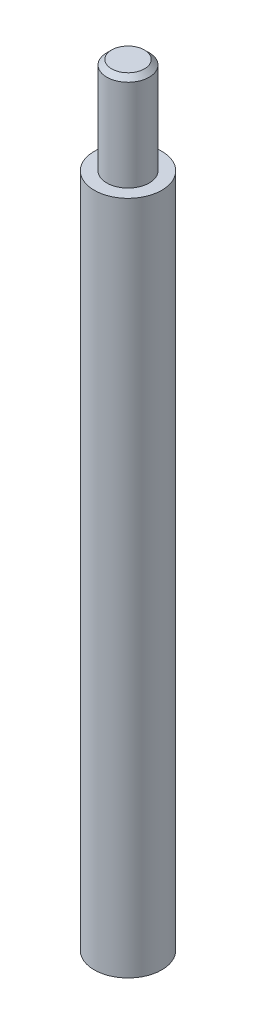
from build123d import *

# Parameters (mm, degrees)
CHAMFER1_SIZE = 0.5


with BuildPart() as part:
    # Sketch1 → Revolve1 (revolve)
    with BuildSketch(Plane.XY):
        Polygon((0, 45), (-2.2, 45), (-2.2, 35), (-3.5, 35), (-3.5, -35), (0, -35), align=None)
    revolve(axis=Axis((0, -495.732162905, 0), (0, 1, 0)))

    # Chamfer1
    chamfer1_edges = [part.edges().sort_by_distance(p)[0] for p in [
        (2.2, 45, 0),
    ]]
    chamfer(chamfer1_edges, length=CHAMFER1_SIZE)


solid = part.part
